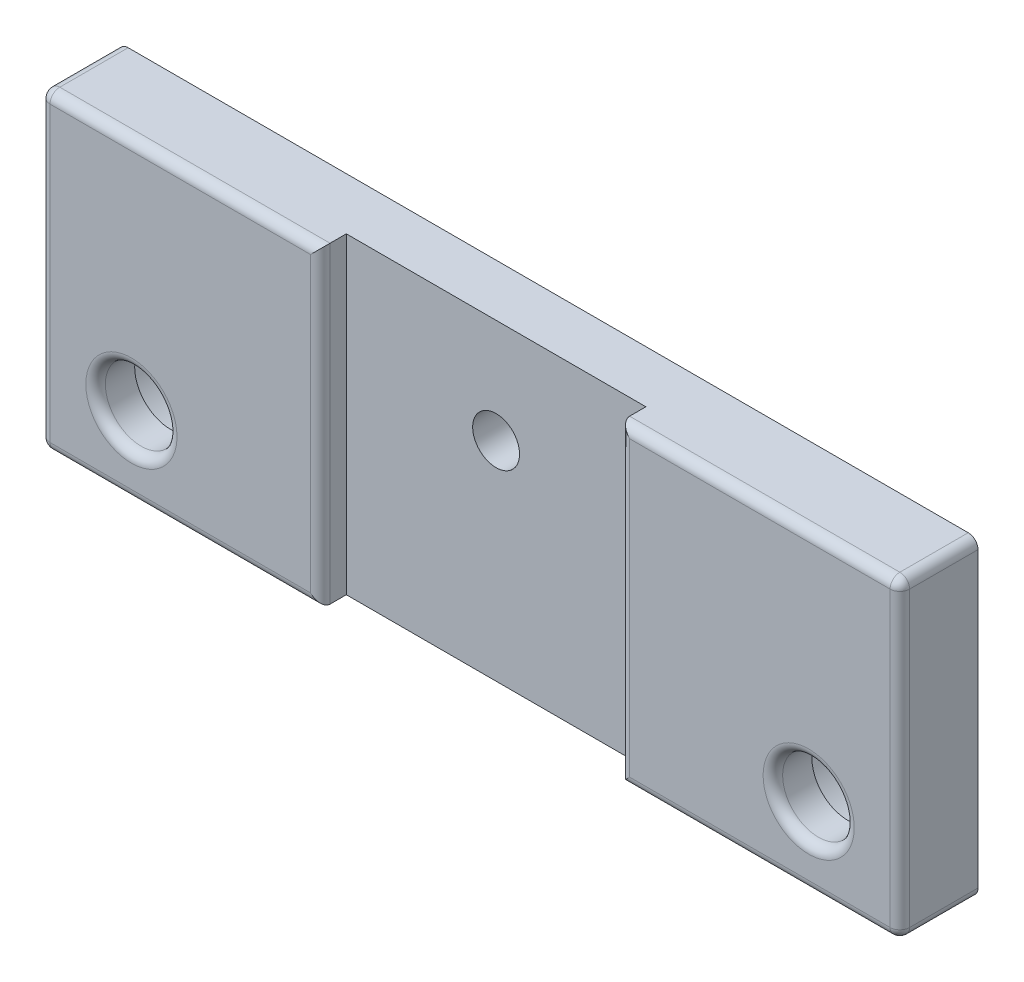
from build123d import *

# Parameters (mm, degrees)
ESQUISSE2_W             = 66
ESQUISSE2_H             = 24
BOSS_EXTRU_1_DEPTH      = 6
ESQUISSE3_W             = 23
ESQUISSE3_H             = 24
ENL_V_MAT_EXTRU_1_DEPTH = 2
ESQUISSE4_R             = 1.8
ENL_V_MAT_EXTRU_2_DEPTH = 5
ESQUISSE5_R             = 2.75
ENL_V_MAT_EXTRU_3_DEPTH = 7
ESQUISSE6_R             = 5.1
ENL_V_MAT_EXTRU_4_DEPTH = 3
CONG_1_R                = 0.75


with BuildPart() as part:
    # Esquisse2 → Boss.-Extru.1 (new body)
    with BuildSketch(Plane.XY):
        with Locations((33, 12)):
            Rectangle(ESQUISSE2_W, ESQUISSE2_H)
    extrude(amount=BOSS_EXTRU_1_DEPTH)

    # Esquisse3 → Enlèv. mat.-Extru.1 (cut)
    with BuildSketch(Plane.XY.offset(6)):
        with Locations((33, 12)):
            Rectangle(ESQUISSE3_W, ESQUISSE3_H)
    extrude(amount=-ENL_V_MAT_EXTRU_1_DEPTH, mode=Mode.SUBTRACT)

    # Esquisse4 → Enlèv. mat.-Extru.2 (cut, through all)
    with BuildSketch(Plane.XY.offset(4)):
        with Locations((33, 16)):
            Circle(ESQUISSE4_R)
    extrude(amount=-ENL_V_MAT_EXTRU_2_DEPTH, mode=Mode.SUBTRACT)

    # Esquisse5 → Enlèv. mat.-Extru.3 (cut, through all)
    with BuildSketch(Plane(origin=(0, 0, 0), x_dir=(-1, 0, 0), z_dir=(0, 0, -1))):
        with Locations((-59, 6)):
            Circle(ESQUISSE5_R)
        with Locations((-7, 6)):
            Circle(ESQUISSE5_R)
    extrude(amount=-ENL_V_MAT_EXTRU_3_DEPTH, mode=Mode.SUBTRACT)

    # Esquisse6 → Enlèv. mat.-Extru.4 (cut)
    with BuildSketch(Plane(origin=(0, 0, 0), x_dir=(-1, 0, 0), z_dir=(0, 0, -1))):
        with Locations((-59, 6)):
            Circle(ESQUISSE6_R)
        with Locations((-7, 6)):
            Circle(ESQUISSE6_R)
    extrude(amount=-ENL_V_MAT_EXTRU_4_DEPTH, mode=Mode.SUBTRACT)

    # Congé1
    cong_1_edges = [part.edges().sort_by_distance(p)[0] for p in [
        (66, 12, 6),
        (55.25, 24, 6),
        (55.25, 0, 6),
        (10.75, 24, 6),
        (21.5, 12, 6),
        (44.5, 12, 6),
        (61.75, 6, 6),
        (9.75, 6, 6),
        (0, 12, 6),
        (10.75, 0, 6),
        (0, 24, 3),
        (66, 24, 3),
        (66, 0, 3),
        (0, 0, 3),
    ]]
    fillet(cong_1_edges, radius=CONG_1_R)


solid = part.part
